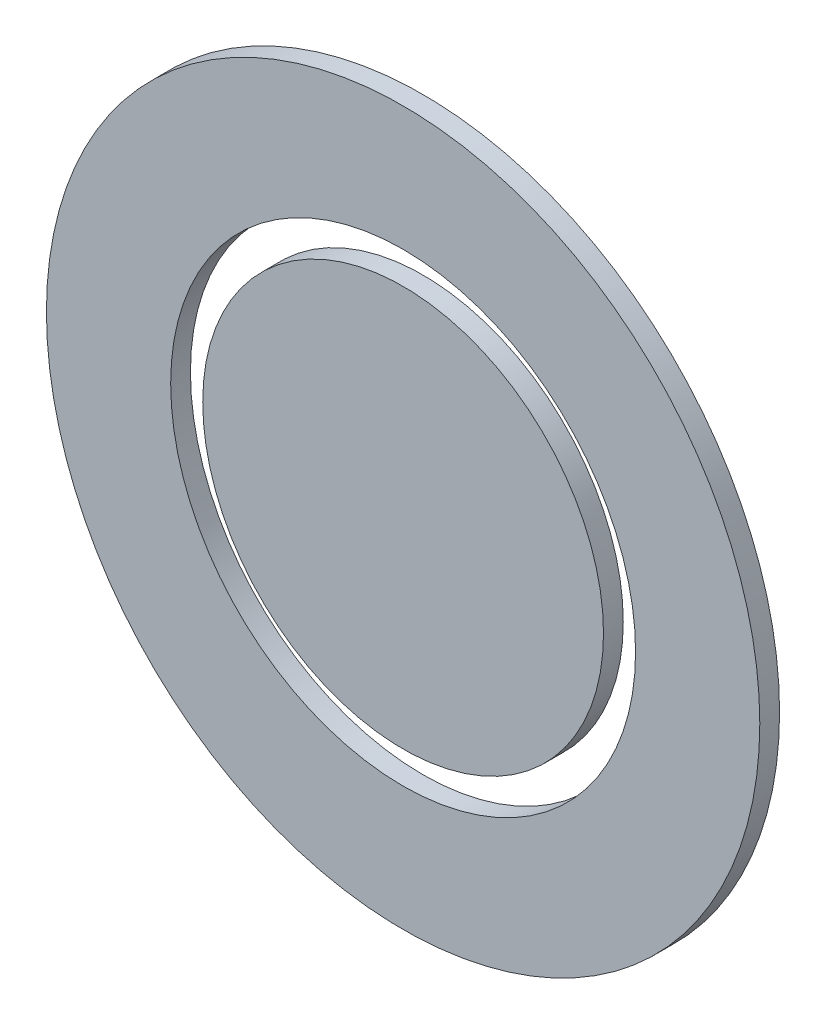
from build123d import *

# Parameters (mm, degrees)
SKETCH1_R           = 75
BOSS_EXTRUDE1_DEPTH = 7.4
SKETCH1_3_R         = 133.5
SKETCH1_3_R_2       = 87
BOSS_EXTRUDE2_DEPTH = 7.4


with BuildPart() as part:
    # Sketch1 → Boss-Extrude1 (new body)
    with BuildSketch(Plane.XY):
        Circle(SKETCH1_R)
    extrude(amount=BOSS_EXTRUDE1_DEPTH)


with BuildPart() as body_2:
    # Sketch1_3 → Boss-Extrude2 (new body)
    with BuildSketch(Plane.XY):
        Circle(SKETCH1_3_R)
        Circle(SKETCH1_3_R_2, mode=Mode.SUBTRACT)
    extrude(amount=BOSS_EXTRUDE2_DEPTH)


solid = Compound([part.part, body_2.part])
